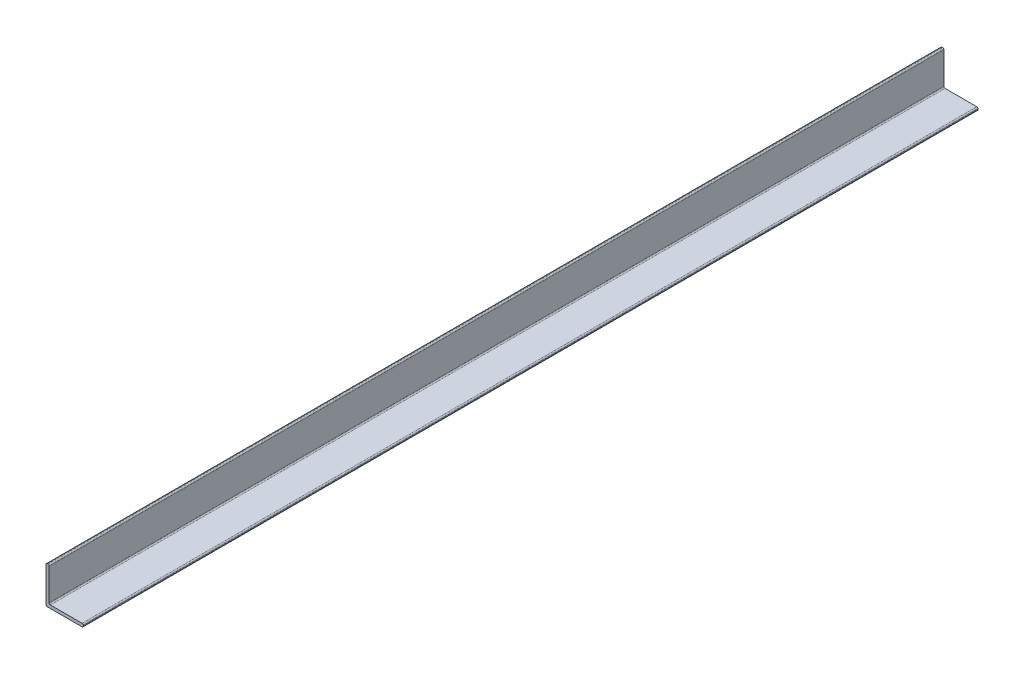
from build123d import *

# Parameters (mm, degrees)
BOSS_EXTRUDE1_DEPTH      = 914.4
BOSS_EXTRUDE1_DEPTH_BACK = 914.4
FILLET1_R                = 2.54


with BuildPart() as part:
    # Sketch4 → Boss-Extrude1 (new body, two sides)
    with BuildSketch(Plane.XY) as boss_extrude1_sk:
        with BuildLine():
            Line((-31.75, -29.21), (-31.75, 38.1))
            Line((-31.75, 38.1), (-38.1, 38.1))
            Line((-38.1, 38.1), (-38.1, -38.1))
            Line((-38.1, -38.1), (38.1, -38.1))
            Line((38.1, -38.1), (38.1, -31.75))
            Line((38.1, -31.75), (-29.21, -31.75))
            ThreePointArc((-29.21, -31.75), (-31.006051224, -31.006051224), (-31.75, -29.21))
        make_face()
    extrude(amount=BOSS_EXTRUDE1_DEPTH)
    extrude(boss_extrude1_sk.sketch, amount=-BOSS_EXTRUDE1_DEPTH_BACK)

    # Fillet1
    fillet1_edges = [part.edges().sort_by_distance(p)[0] for p in [
        (-31.75, 38.1, 0),
        (38.1, -31.75, 0),
        (38.1, -38.1, 0),
        (-38.1, -38.1, 0),
        (-38.1, 38.1, 0),
    ]]
    fillet(fillet1_edges, radius=FILLET1_R)


solid = part.part
